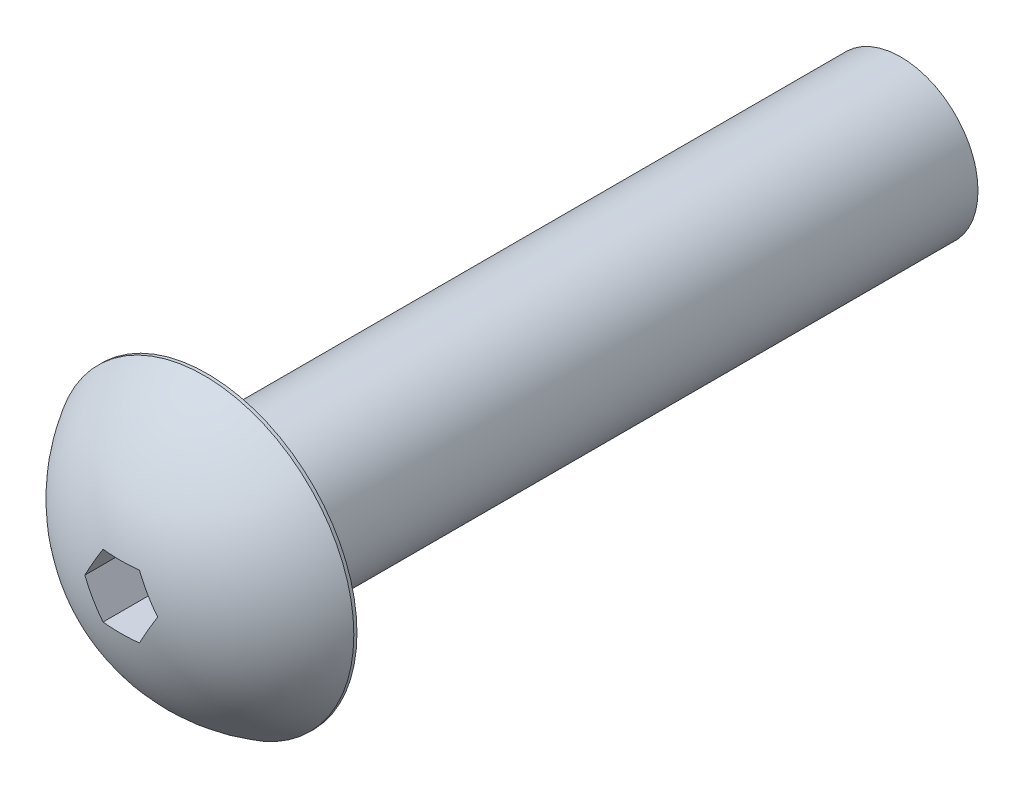
from build123d import *

# Parameters (mm, degrees)
SKETCH1_R            = 2.45
BOSS_SHAFT_DEPTH     = 22
SKETCH2_R            = 4.75
BOSS_HEAD_BASE_DEPTH = 0.1
DOME_M5_FACE_RADIUS  = 4.75
DOME_M5_HEIGHT       = 2.75
CUT_HEX_DEPTH        = 3.85


with BuildPart() as part:
    # Sketch1 → Boss-Shaft (new body)
    with BuildSketch(Plane.XY):
        Circle(SKETCH1_R)
    extrude(amount=BOSS_SHAFT_DEPTH)

    # Sketch2 → Boss-Head Base (add)
    with BuildSketch(Plane.XY.offset(22)):
        Circle(SKETCH2_R)
    extrude(amount=BOSS_HEAD_BASE_DEPTH)

    # Dome-M5: a dome of height H over a round flat face of radius A is a cap of a sphere of radius (A * A + H * H) / (2 * H)
    dome_m5_r = (DOME_M5_FACE_RADIUS * DOME_M5_FACE_RADIUS + DOME_M5_HEIGHT * DOME_M5_HEIGHT) / (2 * DOME_M5_HEIGHT)
    dome_m5_base = Plane((0, 0, 22.1), z_dir=(0, 0, 1))
    with Locations(dome_m5_base.offset(DOME_M5_HEIGHT - dome_m5_r)):
        dome_m5_ball = Sphere(dome_m5_r, mode=Mode.PRIVATE)
    add(split(dome_m5_ball, bisect_by=dome_m5_base, keep=Keep.TOP, mode=Mode.PRIVATE))

    # Sketch3 → Cut-Hex (cut, through all)
    with BuildSketch(Plane(origin=(0, 0, 22), x_dir=(-1, 0, 0), z_dir=(0, 0, -1))):
        Polygon((-0.577350269, 1), (-1.154700538, 0), (-0.577350269, -1), (0.577350269, -1), (1.154700538, 0), (0.577350269, 1), align=None)
    extrude(amount=-CUT_HEX_DEPTH, mode=Mode.SUBTRACT)


solid = part.part
